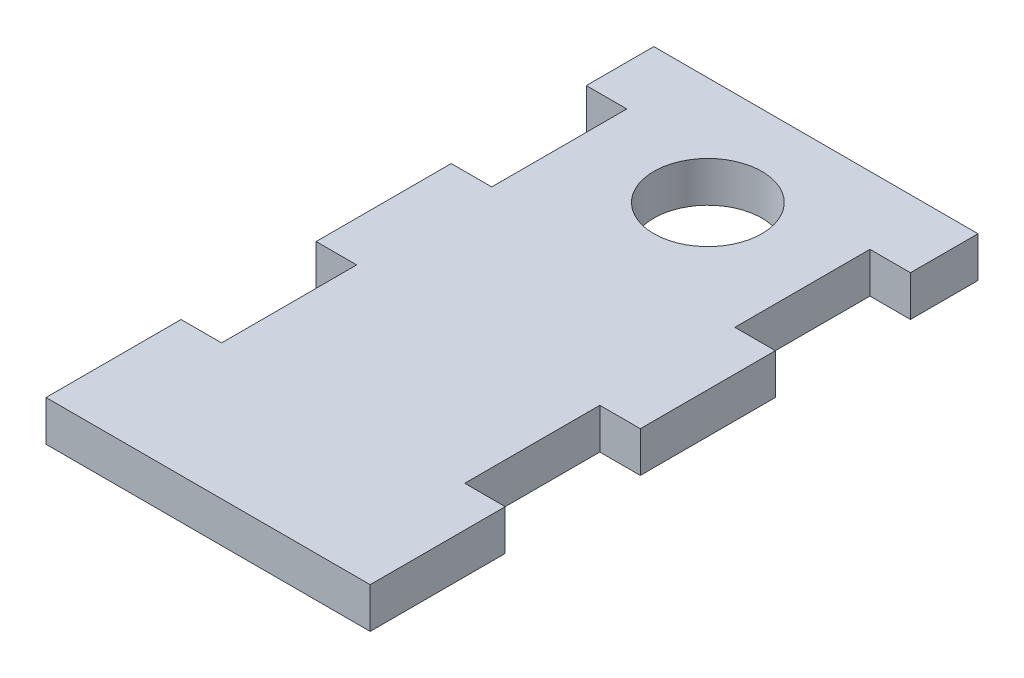
from build123d import *

# Parameters (mm, degrees)
SKETCH1_W           = 24
SKETCH1_H           = 45
BOSS_EXTRUDE1_DEPTH = 3
SKETCH4_R           = 4
SKETCH4_W           = 3
SKETCH4_H           = 10
CUT_EXTRUDE1_DEPTH  = 4


with BuildPart() as part:
    # Sketch1 → Boss-Extrude1 (new body)
    with BuildSketch(Plane(origin=(0, 0, 0), x_dir=(1, 0, 0), z_dir=(0, 1, 0))):
        Rectangle(SKETCH1_W, SKETCH1_H)
    extrude(amount=BOSS_EXTRUDE1_DEPTH)

    # Sketch4 → Cut-Extrude1 (cut, through all)
    with BuildSketch(Plane(origin=(0, 3, 0), x_dir=(1, 0, 0), z_dir=(0, 1, 0))):
        with Locations((0, 14.5)):
            Circle(SKETCH4_R)
        with Locations((-10.5, -7.5)):
            Rectangle(SKETCH4_W, SKETCH4_H)
        with Locations((-10.5, 12.5)):
            Rectangle(SKETCH4_W, SKETCH4_H)
        with Locations((10.5, 12.5)):
            Rectangle(SKETCH4_W, SKETCH4_H)
        with Locations((10.5, -7.5)):
            Rectangle(SKETCH4_W, SKETCH4_H)
    extrude(amount=-CUT_EXTRUDE1_DEPTH, mode=Mode.SUBTRACT)


solid = part.part
